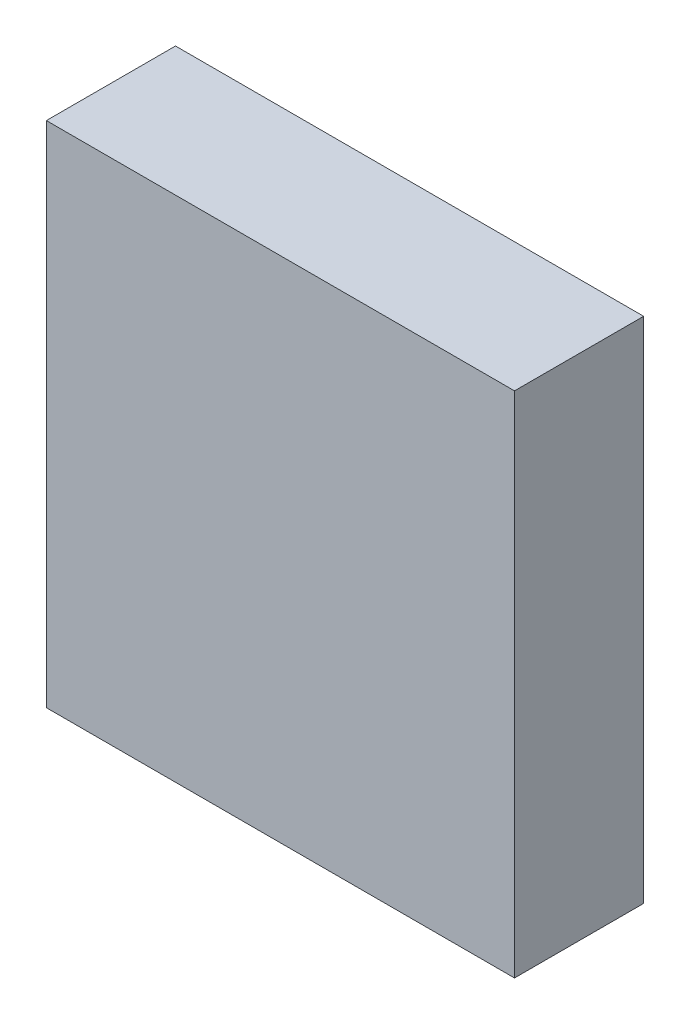
from build123d import *

# Parameters (mm, degrees)
SKETCH1_W           = 58
SKETCH1_H           = 63
BOSS_EXTRUDE1_DEPTH = 16
SKETCH2_W           = 4.7625
SKETCH2_H           = 6.35
BOSS_EXTRUDE2_DEPTH = 6.35


with BuildPart() as part:
    # Sketch1 → Boss-Extrude1 (new body)
    with BuildSketch(Plane.XY):
        with Locations((29, 31.5)):
            Rectangle(SKETCH1_W, SKETCH1_H)
    extrude(amount=BOSS_EXTRUDE1_DEPTH)

    # Sketch2 → Boss-Extrude2 (add)
    with BuildSketch(Plane.ZY):
        with Locations((2.38125, 47.125)):
            Rectangle(SKETCH2_W, SKETCH2_H)
    extrude(amount=BOSS_EXTRUDE2_DEPTH)


solid = part.part
